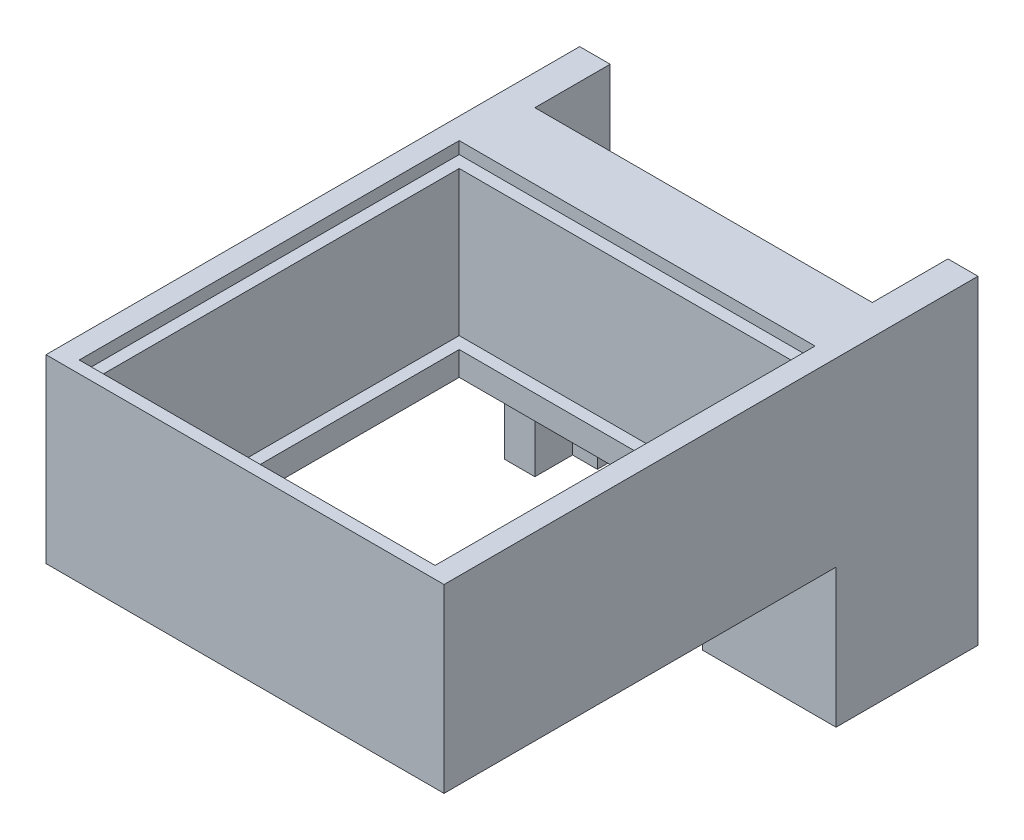
from build123d import *

# Parameters (mm, degrees)
SKETCH_1_W          = 33
SKETCH_1_H          = 38
SKETCH_1_W_2        = 27.5
SKETCH_1_H_2        = 29.5
EXTRUDE_1_DEPTH     = 15
SKETCH_1_3_W        = 27.5
SKETCH_1_3_H        = 29.5
SKETCH_1_3_W_2      = 16
SKETCH_1_3_H_2      = 26.5
EXTRUDE_2_DEPTH     = 2
SKETCH_2_W          = 29.5
SKETCH_2_H          = 31.5
CUT_EXTRUDE_1_DEPTH = 1
SKETCH_3_W          = 11.060472634
SKETCH_3_H          = 5.5
EXTRUDE_3_DEPTH     = 11.5
EXTRUDE_4_DEPTH     = 9.1
SKETCH_5_W          = 2.491276019
SKETCH_5_H          = 6.268810469
EXTRUDE_5_DEPTH     = 17.4
SKETCH_6_W          = 2.530660276
SKETCH_6_H          = 6.244059343
EXTRUDE_6_DEPTH     = 26.5
SKETCH_6_3_W        = 2.054656533
SKETCH_6_3_H        = 3.122029671
EXTRUDE_7_DEPTH     = 9.1


with BuildPart() as part:
    # Sketch 1 → Extrude 1 (new body)
    with BuildSketch(Plane(origin=(0, 0, 0), x_dir=(1, 0, 0), z_dir=(0, 1, 0))):
        with Locations((-34.189708408, -6.844356319)):
            Rectangle(SKETCH_1_W, SKETCH_1_H)
        with Locations((-34.180787321, -9.094356319)):
            Rectangle(SKETCH_1_W_2, SKETCH_1_H_2, mode=Mode.SUBTRACT)
    extrude(amount=EXTRUDE_1_DEPTH)

    # Sketch 1_3 → Extrude 2 (add)
    with BuildSketch(Plane(origin=(0, 0, 0), x_dir=(1, 0, 0), z_dir=(0, 1, 0))):
        with Locations((-34.180787321, -9.094356319)):
            Rectangle(SKETCH_1_3_W, SKETCH_1_3_H)
        with Locations((-38.930787321, -8.594356319)):
            Rectangle(SKETCH_1_3_W_2, SKETCH_1_3_H_2, mode=Mode.SUBTRACT)
        Polygon((-26.430787321, -11.844851054), (-26.430787321, -15.844356319), (-29.430787321, -15.844356319), (-29.43078728, -11.844356319), align=None, mode=Mode.SUBTRACT)
    extrude(amount=EXTRUDE_2_DEPTH)

    # Sketch 2 → Cut-Extrude 1 (cut)
    with BuildSketch(Plane(origin=(0, 15, 0), x_dir=(1, 0, 0), z_dir=(0, 1, 0))):
        with Locations((-34.180787321, -9.094356319)):
            Rectangle(SKETCH_2_W, SKETCH_2_H)
    extrude(amount=-CUT_EXTRUDE_1_DEPTH, mode=Mode.SUBTRACT)

    # Sketch 3 → Extrude 3 (add)
    with BuildSketch(Plane.XZ):
        with Locations((-23.219944725, -9.405643681)):
            Rectangle(SKETCH_3_W, SKETCH_3_H)
    extrude(amount=EXTRUDE_3_DEPTH)

    # Sketch 4 → Extrude 4 (add)
    with BuildSketch(Plane.XZ.offset(11.5)):
        Polygon((-17.689708408, -12.155643681), (-20.180984427, -12.155643681), (-20.180984427, -15.342965437), (-22.327356321, -15.342965437), (-22.327356321, -18.42445415), (-20.180984427, -18.42445415), (-17.689708408, -18.42445415), align=None)
    extrude(amount=-EXTRUDE_4_DEPTH)

    # Sketch 5 → Extrude 5 (add)
    with BuildSketch(Plane(origin=(0, -2.4, 0), x_dir=(1, 0, 0), z_dir=(0, 1, 0))):
        with Locations((-18.935346417, 15.290048916)):
            Rectangle(SKETCH_5_W, SKETCH_5_H)
    extrude(amount=EXTRUDE_5_DEPTH)

    # Sketch 6 → Extrude 6 (add)
    with BuildSketch(Plane.XZ.offset(11.5)):
        with Locations((-49.42437827, -15.277673353)):
            Rectangle(SKETCH_6_W, SKETCH_6_H)
    extrude(amount=-EXTRUDE_6_DEPTH)

    # Sketch 6_3 → Extrude 7 (add)
    with BuildSketch(Plane.XZ.offset(11.5)):
        with Locations((-47.131719866, -16.838688189)):
            Rectangle(SKETCH_6_3_W, SKETCH_6_3_H)
    extrude(amount=-EXTRUDE_7_DEPTH)


solid = part.part
